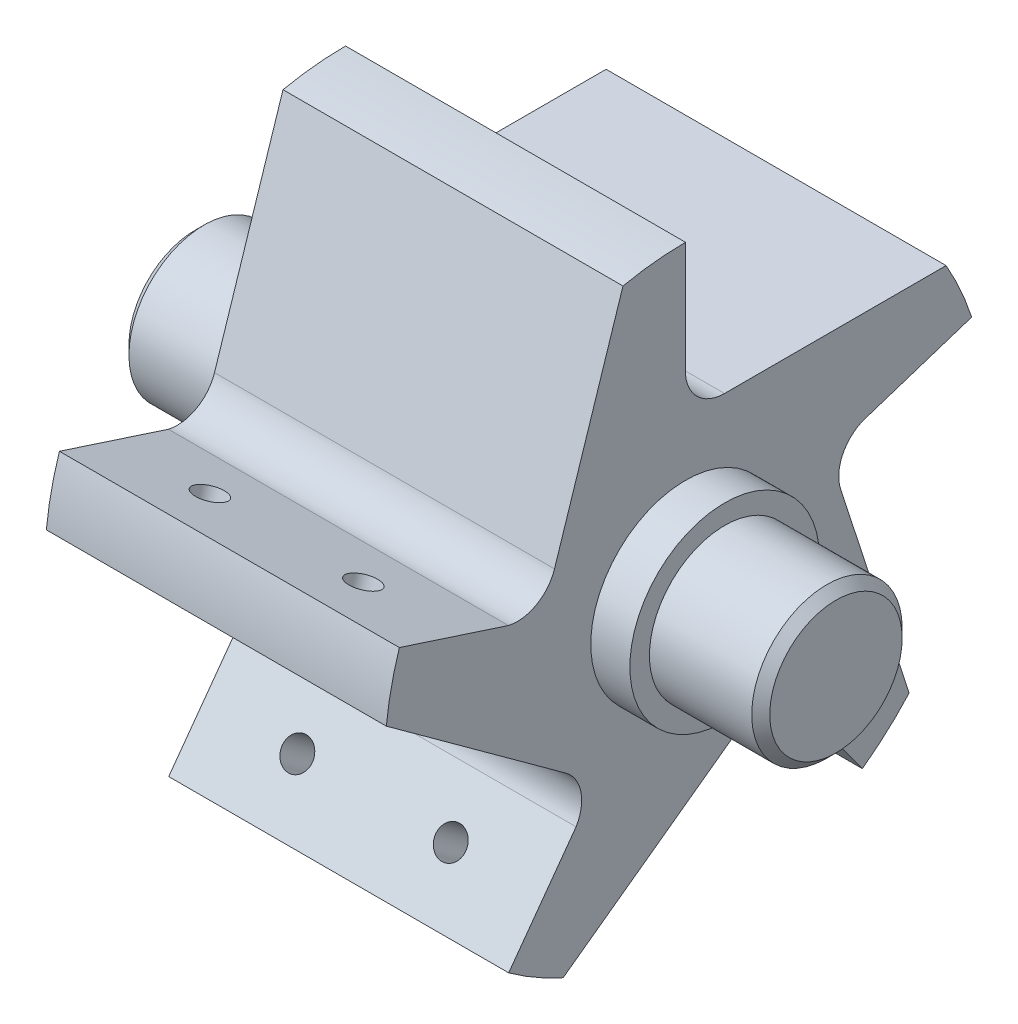
from build123d import *

# Parameters (mm, degrees)
BOSS_EXTRUDE1_DEPTH      = 28.702
SKETCH9_R                = 8.001
SKETCH9_R_2              = 6.35
BOSS_EXTRUDE2_DEPTH      = 3.302
SKETCH16_R               = 6.35
BOSS_EXTRUDE3_DEPTH      = 12.7
CHAMFER1_SIZE            = 0.762
CHAMFER1_OF_MIRROR1_SIZE = 0.762
SKETCH17_R               = 1.27
CUT_EXTRUDE1_DEPTH       = 4.572
CIRPATTERN1_COUNT        = 5


with BuildPart() as part:
    # Sketch1 → Boss-Extrude1 (new body)
    with BuildSketch(Plane(origin=(0, 0, 0), x_dir=(0, 0, -1), z_dir=(1, 0, 0))):
        with BuildLine():
            Line((0, 15.718274541), (0, 25.4))
            ThreePointArc((0, 25.4), (-2.655022967, 25.260856142), (-5.280956947, 24.844949059))
            Line((-5.280956947, 24.844949059), (-11.061817414, 7.053289967))
            ThreePointArc((-11.061817414, 7.053289967), (-12.577998446, 5.198746045), (-14.948967427, 4.857213955))
            Line((-14.948967427, 4.857213955), (-24.156835514, 7.849031657))
            ThreePointArc((-24.156835514, 7.849031657), (-24.844949059, 5.280956947), (-25.260856142, 2.655022967))
            Line((-25.260856142, 2.655022967), (-10.126366954, -8.340827068))
            ThreePointArc((-10.126366954, -8.340827068), (-8.831116578, -10.355886507), (-9.238969967, -12.716351226))
            Line((-9.238969967, -12.716351226), (-14.929745408, -20.549031657))
            ThreePointArc((-14.929745408, -20.549031657), (-12.7, -21.997045256), (-10.331110734, -23.204054624))
            Line((-10.331110734, -23.204054624), (4.803378454, -12.208204589))
            ThreePointArc((4.803378454, -12.208204589), (7.120068242, -11.59903589), (9.238969967, -12.716351226))
            Line((9.238969967, -12.716351226), (14.929745408, -20.549031657))
            ThreePointArc((14.929745408, -20.549031657), (16.995917402, -18.875878567), (18.875878567, -16.995917402))
            Line((18.875878567, -16.995917402), (13.095018099, 0.79574169))
            ThreePointArc((13.095018099, 0.79574169), (13.231560754, 3.18728809), (14.948967427, 4.857213955))
            Line((14.948967427, 4.857213955), (24.156835514, 7.849031657))
            ThreePointArc((24.156835514, 7.849031657), (23.204054624, 10.331110734), (21.997045256, 12.7))
            Line((21.997045256, 12.7), (3.289787814, 12.7))
            ThreePointArc((3.289787814, 12.7), (1.057486028, 13.568888261), (0, 15.718274541))
        make_face()
    extrude(amount=BOSS_EXTRUDE1_DEPTH)

    # Sketch9 → Boss-Extrude2 (add)
    with BuildSketch(Plane(origin=(28.702, 0, 0), x_dir=(0, 0, -1), z_dir=(1, 0, 0))):
        Circle(SKETCH9_R)
        Circle(SKETCH9_R_2, mode=Mode.SUBTRACT)
    boss_extrude2 = extrude(amount=BOSS_EXTRUDE2_DEPTH)

    # Sketch16 → Boss-Extrude3 (add)
    with BuildSketch(Plane(origin=(28.702, 0, 0), x_dir=(0, 0, -1), z_dir=(1, 0, 0))):
        Circle(SKETCH16_R)
    boss_extrude3 = extrude(amount=BOSS_EXTRUDE3_DEPTH)

    # Chamfer1
    chamfer1_edges = [part.edges().sort_by_distance(p)[0] for p in [
        (41.402, 0, 6.35),
    ]]
    chamfer(chamfer1_edges, length=CHAMFER1_SIZE)

    # Mirror1: Boss-Extrude2, Boss-Extrude3 across plane
    add(boss_extrude2.mirror(Plane(origin=(14.351, 0, 0), x_dir=(0, 0, 1), z_dir=(1, 0, 0))))
    add(boss_extrude3.mirror(Plane(origin=(14.351, 0, 0), x_dir=(0, 0, 1), z_dir=(1, 0, 0))))

    # Chamfer1 of Mirror1
    chamfer1_of_mirror1_edges = [part.edges().sort_by_distance(p)[0] for p in [
        (-12.7, 0, 6.35),
    ]]
    chamfer(chamfer1_of_mirror1_edges, length=CHAMFER1_OF_MIRROR1_SIZE)

    # Sketch17 → Cut-Extrude1 (cut)
    with BuildSketch(Plane(origin=(0, 0, 0), x_dir=(-1, 0, 0), z_dir=(0, 0, -1))):
        with Locations((-20.828, 20.32)):
            Circle(SKETCH17_R)
        with Locations((-7.874, 20.32)):
            Circle(SKETCH17_R)
    cut_extrude1 = extrude(amount=-CUT_EXTRUDE1_DEPTH, mode=Mode.SUBTRACT)

    # CirPattern1: Cut-Extrude1 ×5 about axis
    cirpattern1_axis = Axis((0, 0, 0), (1, 0, 0))
    for i in range(1, CIRPATTERN1_COUNT):
        add(cut_extrude1.rotate(cirpattern1_axis, i * 360 / CIRPATTERN1_COUNT), mode=Mode.SUBTRACT)


solid = part.part
